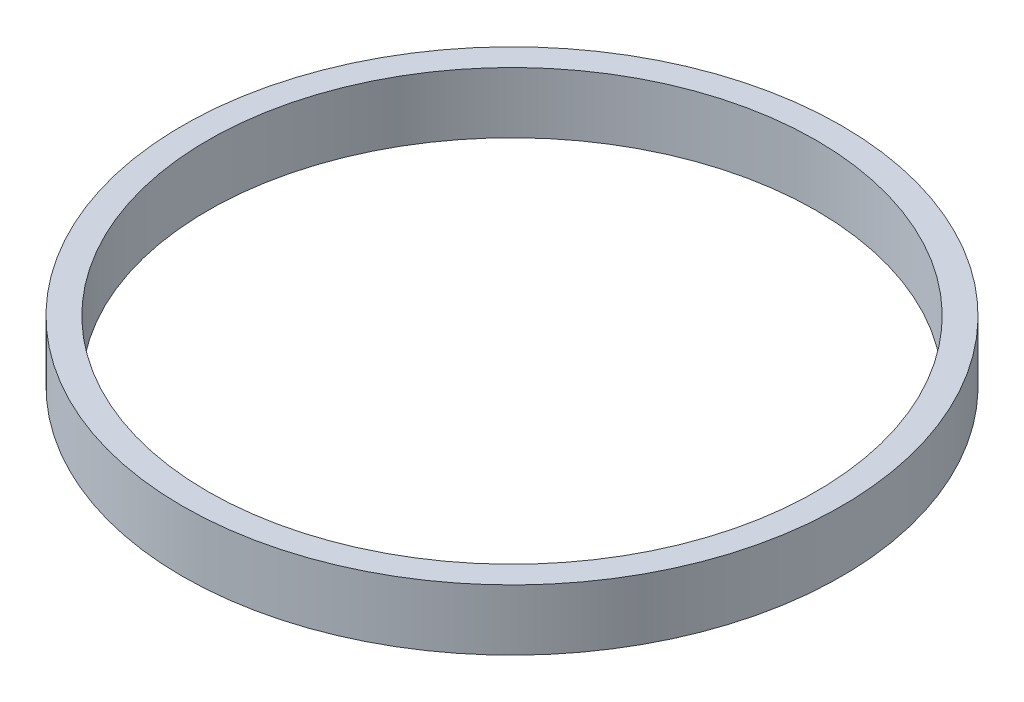
from build123d import *

# Parameters (mm, degrees)
SKETCH1_R           = 32.5
SKETCH1_R_2         = 30
BOSS_EXTRUDE1_DEPTH = 6


with BuildPart() as part:
    # Sketch1 → Boss-Extrude1 (new body)
    with BuildSketch(Plane(origin=(0, 0, 0), x_dir=(1, 0, 0), z_dir=(0, 1, 0))):
        Circle(SKETCH1_R)
        Circle(SKETCH1_R_2, mode=Mode.SUBTRACT)
    extrude(amount=BOSS_EXTRUDE1_DEPTH)


solid = part.part
